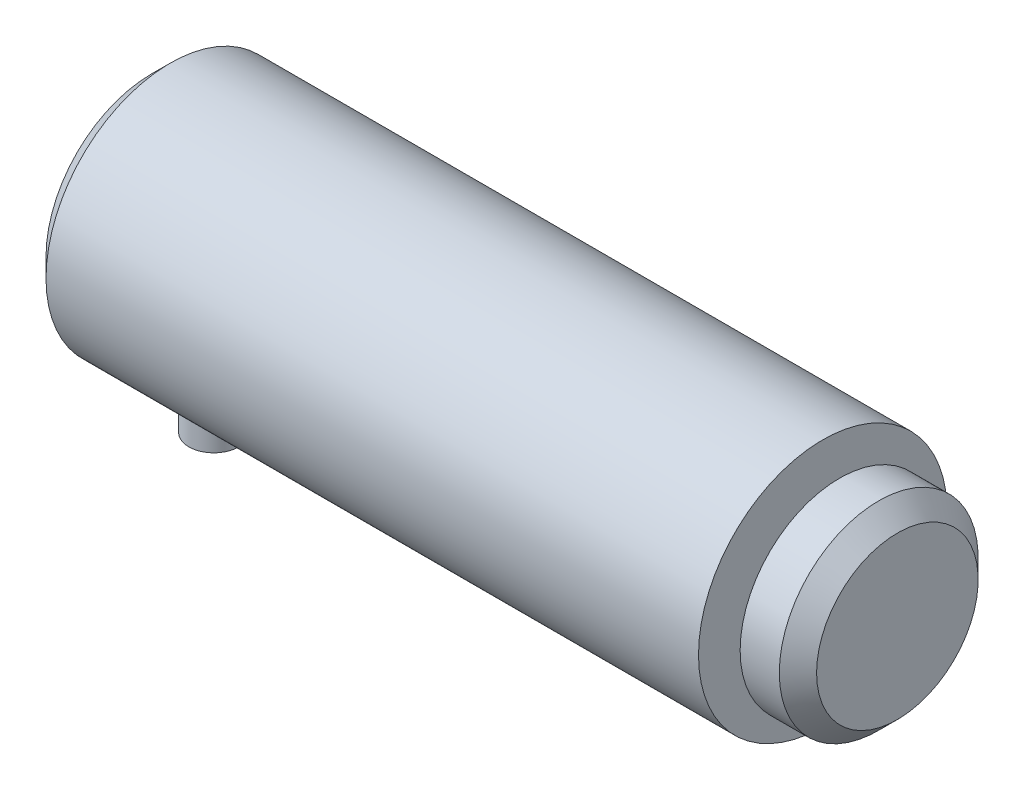
from build123d import *

# Parameters (mm, degrees)
SKETCH1_W           = 54
SKETCH1_H           = 10
SKETCH3_R           = 2
BOSS_EXTRUDE1_DEPTH = 14
SKETCH4_W           = 6
SKETCH4_H           = 8
SKETCH5_W           = 1.35
SKETCH5_H           = 2


with BuildPart() as part:
    # Sketch1 → Revolve1 (revolve)
    with BuildSketch(Plane.XY):
        with Locations((-3, 5)):
            Rectangle(SKETCH1_W, SKETCH1_H)
    revolve(axis=Axis((24, 0, 0), (-1, 0, 0)))

    # Sketch2 → Cut-Revolve1 (revolve, cut)
    with BuildSketch(Plane.XY):
        Polygon((-30, 8.5), (-28.5, 10), (-30, 10), align=None)
    revolve(axis=Axis((49, 0, 0), (-1, 0, 0)), mode=Mode.SUBTRACT)

    # Sketch3 → Boss-Extrude1 (add)
    with BuildSketch(Plane(origin=(0, 0, 0), x_dir=(1, 0, 0), z_dir=(0, 1, 0))):
        with Locations((-25, 0)):
            Circle(SKETCH3_R)
    extrude(amount=-BOSS_EXTRUDE1_DEPTH)

    # Sketch4 → Revolve2 (revolve)
    with BuildSketch(Plane.XY):
        with Locations((27, 4)):
            Rectangle(SKETCH4_W, SKETCH4_H)
    revolve(axis=Axis((30, 0, 0), (-1, 0, 0)))

    # Sketch5 → Cut-Revolve2 (revolve, cut)
    with BuildSketch(Plane.XY):
        with Locations((24.675, 7)):
            Rectangle(SKETCH5_W, SKETCH5_H)
    revolve(axis=Axis((49, 0, 0), (-1, 0, 0)), mode=Mode.SUBTRACT)

    # Sketch6 → Cut-Revolve3 (revolve, cut)
    with BuildSketch(Plane.XY):
        Polygon((28.5, 8), (30, 6.5), (30, 8), align=None)
    revolve(axis=Axis((49, 0, 0), (-1, 0, 0)), mode=Mode.SUBTRACT)


solid = part.part
